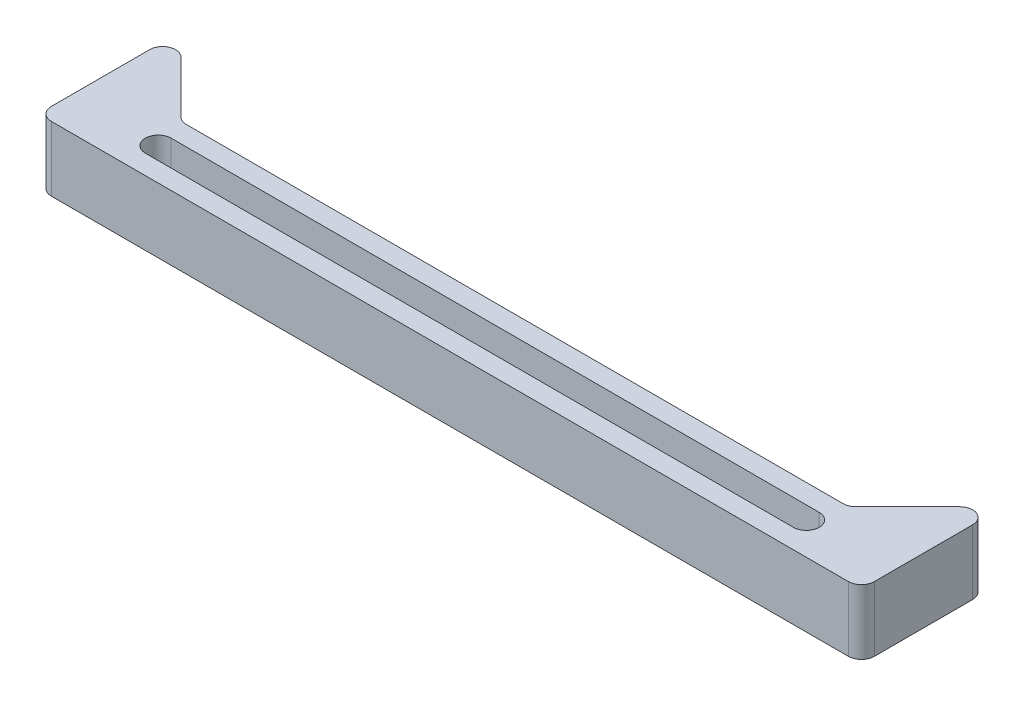
from build123d import *

# Parameters (mm, degrees)
SKETCH1_W           = 127
SKETCH1_H           = 10
BOSS_EXTRUDE1_DEPTH = 10
BOSS_EXTRUDE2_DEPTH = 10
FILLET1_R           = 2
CUT_EXTRUDE1_REACH  = 12


with BuildPart() as part:
    # Sketch1 → Boss-Extrude1 (new body)
    with BuildSketch(Plane(origin=(0, 0, 0), x_dir=(1, 0, 0), z_dir=(0, 1, 0))):
        Rectangle(SKETCH1_W, SKETCH1_H)
    extrude(amount=BOSS_EXTRUDE1_DEPTH)

    # Sketch2 → Boss-Extrude2 (add)
    with BuildSketch(Plane(origin=(0, 10, 0), x_dir=(1, 0, 0), z_dir=(0, 1, 0))):
        Polygon((-63.5, 5), (-63.5, 17), (-51.5, 5), align=None)
        Polygon((51.5, 5), (63.5, 5), (63.5, 17), align=None)
    extrude(amount=-BOSS_EXTRUDE2_DEPTH)

    # Fillet1
    fillet1_edges = [part.edges().sort_by_distance(p)[0] for p in [
        (-51.5, 5, -5),
        (-63.5, 5, -17),
        (51.5, 5, -5),
        (63.5, 5, -17),
        (63.5, 5, 5),
        (-63.5, 5, 5),
    ]]
    fillet(fillet1_edges, radius=FILLET1_R)

    # Sketch4 → Cut-Extrude1 (cut, up to next)
    with BuildSketch(Plane(origin=(0, 10, 0), x_dir=(1, 0, 0), z_dir=(0, 1, 0)), mode=Mode.PRIVATE) as cut_extrude1_sk1:
        with BuildLine():
            Line((-50, 2), (50, 2))
            ThreePointArc((50, 2), (52, 0), (50, -2))
            Line((50, -2), (-50, -2))
            ThreePointArc((-50, -2), (-52, 0), (-50, 2))
        make_face()
    cut_extrude1_tool1 = extrude(cut_extrude1_sk1.sketch, amount=-CUT_EXTRUDE1_REACH, mode=Mode.PRIVATE) & part.part
    add(cut_extrude1_tool1.solids().sort_by_distance((0, 10, 0))[0], mode=Mode.SUBTRACT)


solid = part.part
